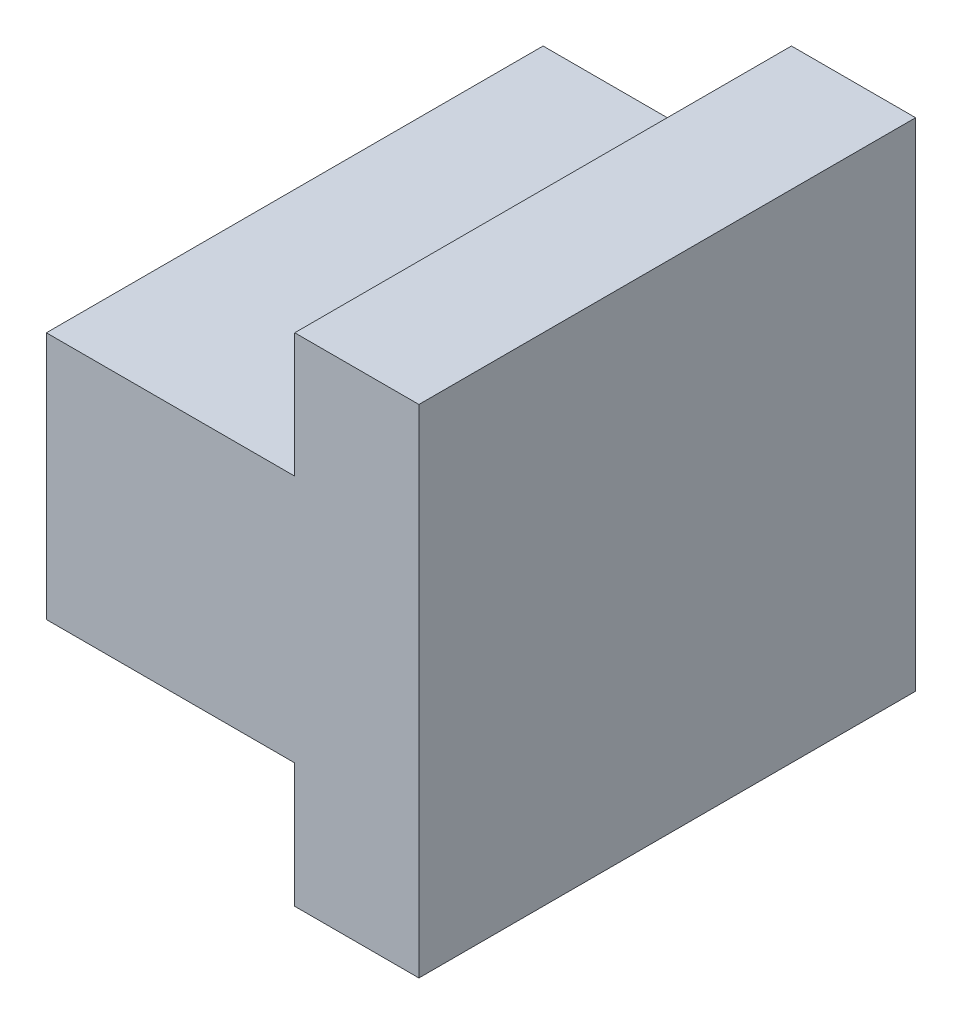
from build123d import *

# Parameters (mm, degrees)
BOSS_EXTRUDE1_DEPTH = 4
SKETCH2_W           = 1
SKETCH2_H           = 3
CUT_EXTRUDE1_DEPTH  = 1


with BuildPart() as part:
    # Sketch1 → Boss-Extrude1 (new body)
    with BuildSketch(Plane.XY):
        Polygon((0, 0), (0, 2), (1, 2), (1, 3), (3, 3), (3, 4), (4, 4), (4, 0), (3, 0), (3, 1), (1, 1), (1, 0), align=None)
    extrude(amount=BOSS_EXTRUDE1_DEPTH)

    # Sketch2 → Cut-Extrude1 (cut)
    with BuildSketch(Plane.XY.offset(4)):
        with Locations((0.5, 1.5)):
            Rectangle(SKETCH2_W, SKETCH2_H)
    extrude(amount=-CUT_EXTRUDE1_DEPTH, mode=Mode.SUBTRACT)


solid = part.part
